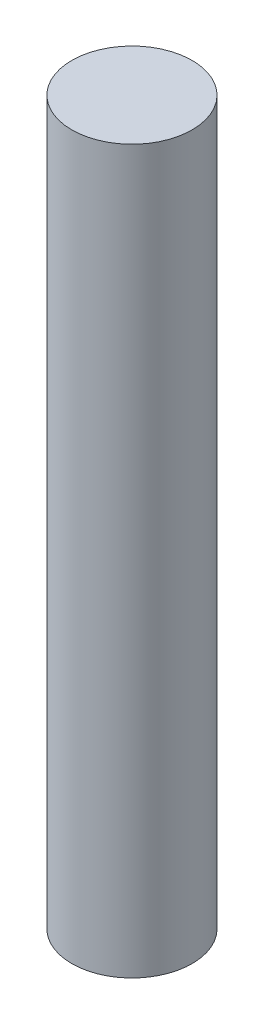
from build123d import *

# Parameters (mm, degrees)
SKETCH1_R           = 3.175
BOSS_EXTRUDE1_DEPTH = 19.05


with BuildPart() as part:
    # Sketch1 → Boss-Extrude1 (new body, symmetric)
    with BuildSketch(Plane(origin=(0, 0, 0), x_dir=(1, 0, 0), z_dir=(0, 1, 0))):
        Circle(SKETCH1_R)
    extrude(amount=BOSS_EXTRUDE1_DEPTH, both=True)


solid = part.part
